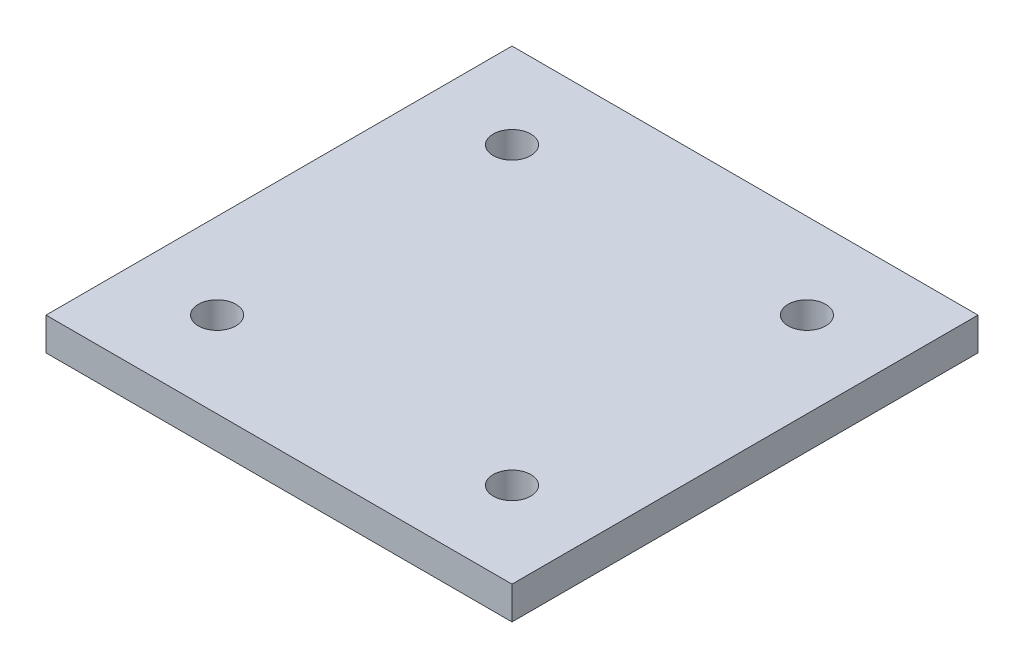
from build123d import *

# Parameters (mm, degrees)
SKETCH1_W           = 28.443085122
SKETCH1_H           = 28.443085122
SKETCH1_R           = 1.146225587
BOSS_EXTRUDE1_DEPTH = 2


with BuildPart() as part:
    # Sketch1 → Boss-Extrude1 (new body)
    with BuildSketch(Plane(origin=(0, 0, 0), x_dir=(1, 0, 0), z_dir=(0, 1, 0))):
        Rectangle(SKETCH1_W, SKETCH1_H)
        with Locations((-9, 9)):
            Circle(SKETCH1_R, mode=Mode.SUBTRACT)
        with Locations((9, 9)):
            Circle(SKETCH1_R, mode=Mode.SUBTRACT)
        with Locations((9, -9)):
            Circle(SKETCH1_R, mode=Mode.SUBTRACT)
        with Locations((-9, -9)):
            Circle(SKETCH1_R, mode=Mode.SUBTRACT)
    extrude(amount=BOSS_EXTRUDE1_DEPTH)


solid = part.part
